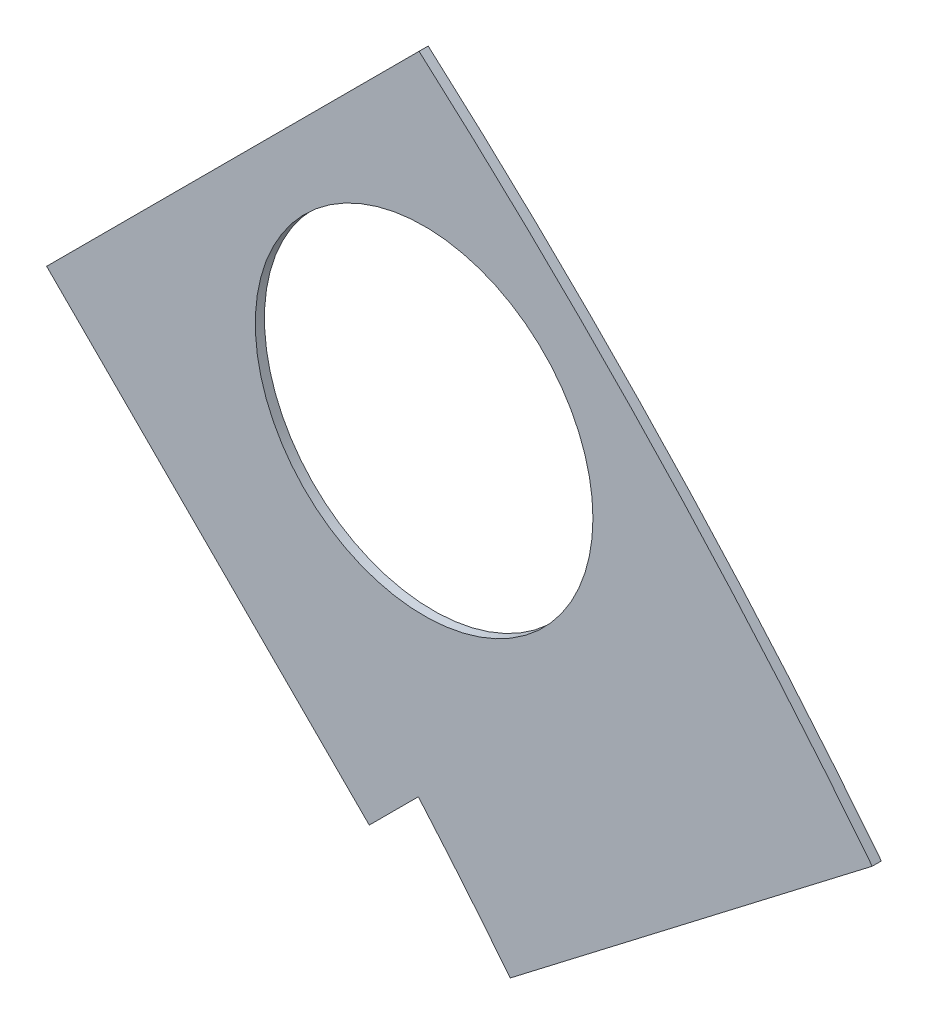
from build123d import *

# Parameters (mm, degrees)
BOSS_EXTRUDE1_DEPTH = 0.254
SKETCH2_R           = 4.699
CUT_EXTRUDE1_DEPTH  = 1.254
SKETCH3_W           = 2.54
SKETCH3_H           = 0.635
CUT_EXTRUDE2_DEPTH  = 1.254
SKETCH5_OUTSIDE_W   = 121.447
SKETCH5_OUTSIDE_H   = 109.618
CUT_EXTRUDE5_DEPTH  = 1.254


with BuildPart() as part:
    # Sketch1 → Boss-Extrude1 (new body)
    with BuildSketch(Plane.XY):
        with BuildLine():
            Line((67.21146711, 76.191723231), (8.696654013, 17.676910134))
            Line((8.696654013, 17.676910134), (7.228954972, 14.133571205))
            ThreePointArc((7.228954972, 14.133571205), (14.666587579, 6.075099489), (15.105587123, -4.88230096))
            Line((15.105587123, -4.88230096), (18.648926052, -6.35))
            Line((18.648926052, -6.35), (101.401368334, -6.35))
            ThreePointArc((101.401368334, -6.35), (93.866160503, 38.880636728), (67.21146711, 76.191723231))
        make_face()
        with BuildLine():
            Line((88.672924278, 6.35), (27.86051193, 6.35))
            ThreePointArc((27.86051193, 6.35), (26.399857642, 10.93517908), (24.190484974, 15.210228852))
            Line((24.190484974, 15.210228852), (67.191354125, 58.211098004))
            ThreePointArc((67.191354125, 58.211098004), (82.13289044, 34.020557137), (88.672924278, 6.35))
        make_face(mode=Mode.SUBTRACT)
    extrude(amount=BOSS_EXTRUDE1_DEPTH)

    # Sketch2 → Cut-Extrude1 (cut, through all)
    with BuildSketch(Plane.XY.offset(0.254)):
        with Locations((22.225, 0)):
            Circle(SKETCH2_R)
        with Locations((36.195, 0)):
            Circle(SKETCH2_R)
        with Locations((61.722, 0)):
            Circle(SKETCH2_R)
        with Locations((75.692, 0)):
            Circle(SKETCH2_R)
        with Locations((95.25, 0)):
            Circle(SKETCH2_R)
        with Locations((15.715448212, 15.715448212)):
            Circle(SKETCH2_R)
        with Locations((25.593729945, 25.593729945)):
            Circle(SKETCH2_R)
        with Locations((43.644044748, 43.644044748)):
            Circle(SKETCH2_R)
        with Locations((53.522326482, 53.522326482)):
            Circle(SKETCH2_R)
        with Locations((92.004434954, 24.652514046)):
            Circle(SKETCH2_R)
        with Locations((82.48891971, 47.625)):
            Circle(SKETCH2_R)
        with Locations((67.351920908, 67.351920908)):
            Circle(SKETCH2_R)
    extrude(amount=-CUT_EXTRUDE1_DEPTH, mode=Mode.SUBTRACT)

    # Sketch3 → Cut-Extrude2 (cut, through all)
    with BuildSketch(Plane.XY.offset(0.254)):
        Polygon((15.266435406, 24.246691527), (17.06248663, 26.042742751), (17.511499436, 25.593729945), (15.715448212, 23.797678721), align=None)
        Polygon((44.991083167, 53.971339288), (43.195031942, 52.175288063), (43.644044748, 51.726275257), (45.440095973, 53.522326482), align=None)
        with Locations((29.21, -6.0325)):
            Rectangle(SKETCH3_W, SKETCH3_H)
        with Locations((68.707, -6.0325)):
            Rectangle(SKETCH3_W, SKETCH3_H)
        Polygon((29.230733674, 38.210989795), (31.026784898, 40.007041019), (31.475797704, 39.558028213), (29.67974648, 37.761976989), align=None)
        Polygon((56.845021246, 65.825277367), (55.048970022, 64.029226143), (55.497982828, 63.580213337), (57.294034052, 65.376264561), align=None)
        with Locations((48.9585, -6.0325)):
            Rectangle(SKETCH3_W, SKETCH3_H)
        with Locations((85.471, -6.0325)):
            Rectangle(SKETCH3_W, SKETCH3_H)
        Polygon((99.935462164, 14.437711971), (100.266998693, 11.919442024), (101.526133667, 12.085210288), (101.194597138, 14.603480236), align=None)
        Polygon((93.765504959, 37.464305742), (94.938831965, 37.950313702), (93.966816047, 40.296967714), (92.793489041, 39.810959755), align=None)
        Polygon((79.327792988, 62.471156422), (80.874047017, 60.456038938), (81.88160576, 61.229165953), (80.33535173, 63.244283437), align=None)
        Polygon((13.593916116, 7.005422516), (14.565932035, 4.658768503), (15.739259041, 5.144776462), (14.767243123, 7.491430475), align=None)
    extrude(amount=-CUT_EXTRUDE2_DEPTH, mode=Mode.SUBTRACT)

    # Sketch5 outside → Cut-Extrude5 (cut, through all)
    with BuildSketch(Plane.XY.offset(0.254)):
        with Locations((54.4145, 34.921)):
            Rectangle(SKETCH5_OUTSIDE_W, SKETCH5_OUTSIDE_H)
        Polygon((55.946995634, 66.72330298), (68.504300263, 54.16599835), (81.410712434, 64.069436727), (67.351920908, 78.128228253), align=None, mode=Mode.SUBTRACT)
    extrude(amount=-CUT_EXTRUDE5_DEPTH, mode=Mode.SUBTRACT)


solid = part.part
